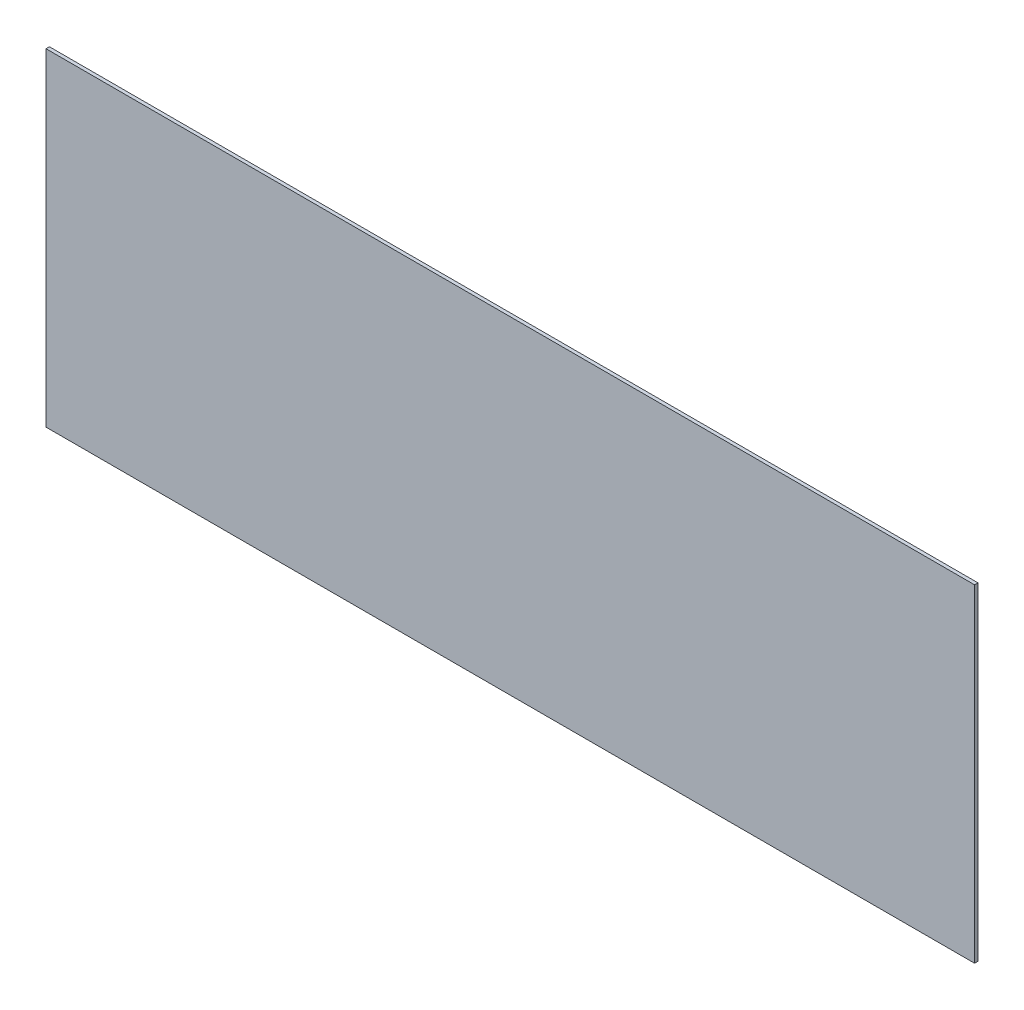
from build123d import *

# Parameters (mm, degrees)
SKETCH1_W           = 863.6
SKETCH1_H           = 304.8
BOSS_EXTRUDE1_DEPTH = 3.175


with BuildPart() as part:
    # Sketch1 → Boss-Extrude1 (new body)
    with BuildSketch(Plane.XY):
        Rectangle(SKETCH1_W, SKETCH1_H)
    extrude(amount=BOSS_EXTRUDE1_DEPTH)


solid = part.part
